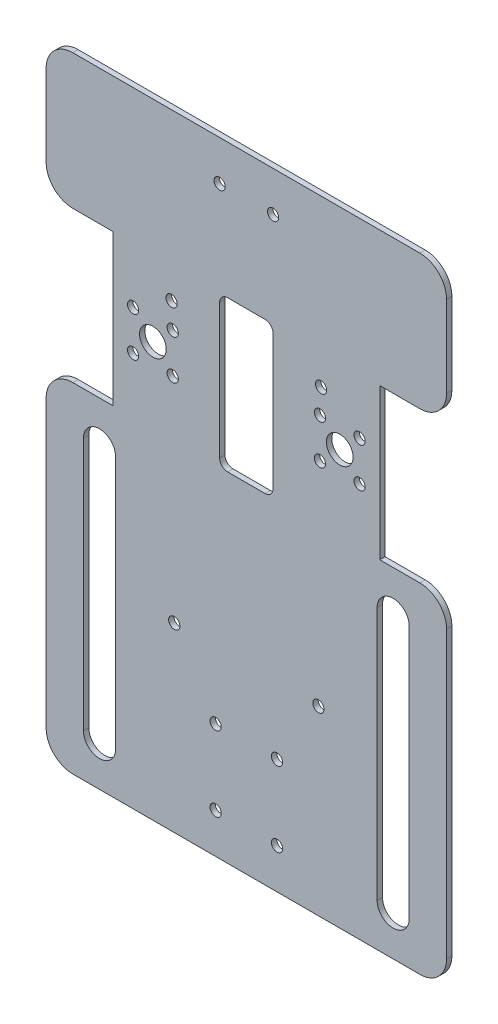
from build123d import *

# Parameters (mm, degrees)
EXTRUDE_1_DEPTH     = 2
FILLET_1_R          = 10
SKETCH_3_R          = 2.1
SKETCH_3_R_2        = 5
CUT_EXTRUDE_1_DEPTH = 3


with BuildPart() as part:
    # 草图1 → 凸台-拉伸1 (new body)
    with BuildSketch(Plane.XY):
        Polygon((75, 117), (-75, 117), (-75, 66.5), (-50, 66.5), (-50, 10), (-75, 10), (-75, -117), (75, -117), (75, 10), (50, 10), (50, 66.5), (75, 66.5), align=None)
        with BuildLine():
            Line((-49, -6), (-49, -101))
            ThreePointArc((-49, -101), (-55, -107), (-61, -101))
            Line((-61, -101), (-61, -6))
            ThreePointArc((-61, -6), (-55, 0), (-49, -6))
        make_face(mode=Mode.SUBTRACT)
        with BuildLine():
            Line((49, -6), (49, -101))
            ThreePointArc((49, -101), (55, -107), (61, -101))
            Line((61, -101), (61, -6))
            ThreePointArc((61, -6), (55, 0), (49, -6))
        make_face(mode=Mode.SUBTRACT)
    extrude(amount=EXTRUDE_1_DEPTH)

    # 圆角1
    fillet_1_edges = [part.edges().sort_by_distance(p)[0] for p in [
        (-75, 117, 1),
        (75, 117, 1),
        (75, 66.5, 1),
        (75, 10, 1),
        (75, -117, 1),
        (-75, -117, 1),
        (-75, 10, 1),
        (-75, 66.5, 1),
    ]]
    fillet(fillet_1_edges, radius=FILLET_1_R)

    # 草图3 → 切除-拉伸1 (cut, through all)
    with BuildSketch(Plane.XY.offset(2)):
        with Locations((-10, 102)):
            Circle(SKETCH_3_R)
        with Locations((-35, 38.25)):
            Circle(SKETCH_3_R_2)
        with Locations((-42.425, 30.825757614)):
            Circle(SKETCH_3_R)
        with Locations((-42.424242386, 45.675)):
            Circle(SKETCH_3_R)
        with Locations((-27.575, 45.674242386)):
            Circle(SKETCH_3_R)
        with Locations((-27.575757614, 30.825)):
            Circle(SKETCH_3_R)
        with Locations((27.575757614, 30.825)):
            Circle(SKETCH_3_R)
        with Locations((27.575, 45.674242386)):
            Circle(SKETCH_3_R)
        with Locations((42.424242386, 45.675)):
            Circle(SKETCH_3_R)
        with Locations((42.425, 30.825757614)):
            Circle(SKETCH_3_R)
        with Locations((35, 38.25)):
            Circle(SKETCH_3_R_2)
        with Locations((10, 102)):
            Circle(SKETCH_3_R)
        with Locations((27, -49)):
            Circle(SKETCH_3_R)
        with Locations((-27, -49)):
            Circle(SKETCH_3_R)
        with Locations((-11.5, -102)):
            Circle(SKETCH_3_R)
        with Locations((11.5, -102)):
            Circle(SKETCH_3_R)
        with Locations((11.5, -74)):
            Circle(SKETCH_3_R)
        with Locations((-11.5, -74)):
            Circle(SKETCH_3_R)
        with Locations((-28, 55)):
            Circle(SKETCH_3_R)
        with Locations((28, 55)):
            Circle(SKETCH_3_R)
        with BuildLine():
            Line((-7, 66.5), (7, 66.5))
            ThreePointArc((7, 66.5), (9.121320344, 65.621320344), (10, 63.5))
            Line((10, 63.5), (10, 13))
            ThreePointArc((10, 13), (9.121320344, 10.878679656), (7, 10))
            Line((7, 10), (-7, 10))
            ThreePointArc((-7, 10), (-9.121320344, 10.878679656), (-10, 13))
            Line((-10, 13), (-10, 63.5))
            ThreePointArc((-10, 63.5), (-9.121320344, 65.621320344), (-7, 66.5))
        make_face()
    extrude(amount=-CUT_EXTRUDE_1_DEPTH, mode=Mode.SUBTRACT)


solid = part.part
